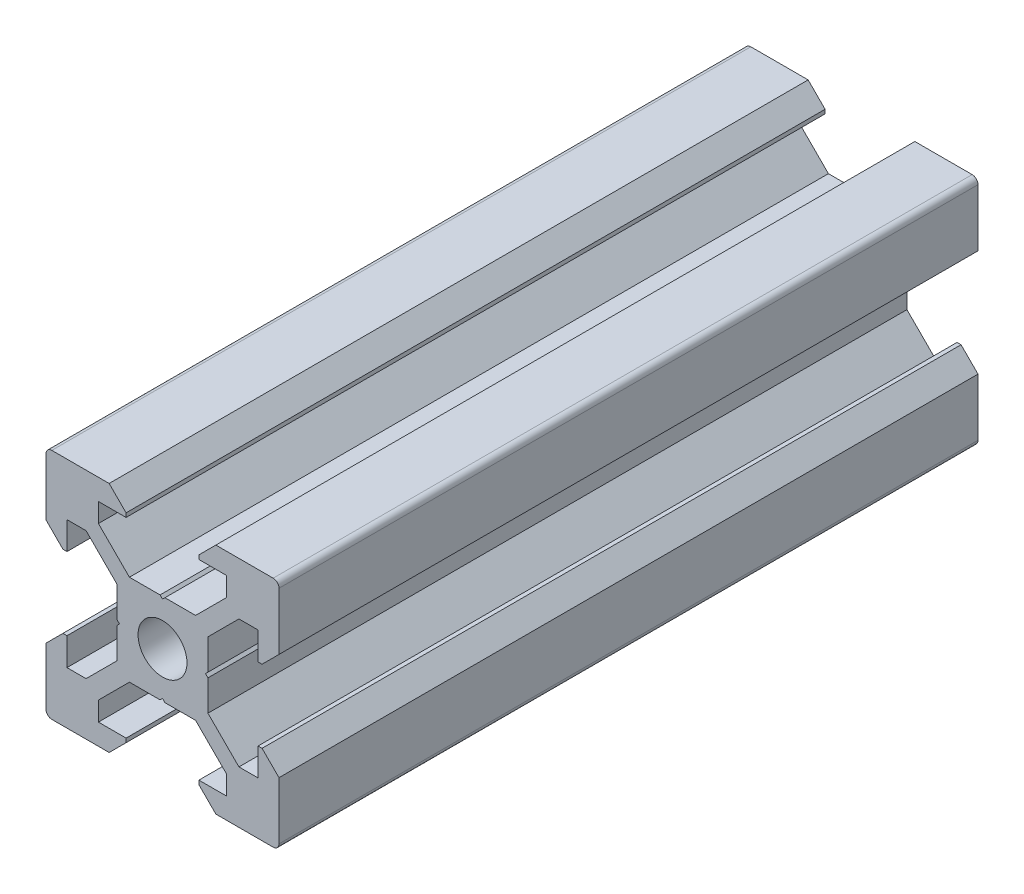
from build123d import *

# Parameters (mm, degrees)
SKETCH1_R           = 2.1
BOSS_EXTRUDE1_DEPTH = 60


with BuildPart() as part:
    # Sketch1 → Boss-Extrude1 (new body)
    with BuildSketch(Plane.XY):
        with BuildLine():
            Line((4.58, -10), (9.5, -10))
            ThreePointArc((9.5, -10), (9.853553391, -9.853553391), (10, -9.5))
            Line((10, -9.5), (10, -4.58))
            Line((10, -4.58), (8.545, -3.125))
            Line((8.545, -3.125), (8.2, -3.125))
            Line((8.2, -3.125), (8.2, -5.5))
            Line((8.2, -5.5), (6.560660172, -5.5))
            Line((6.560660172, -5.5), (3.9, -2.839339828))
            Line((3.9, -2.839339828), (3.9, -0.21))
            Line((3.9, -0.21), (3.69, 0))
            Line((3.69, 0), (3.9, 0.21))
            Line((3.9, 0.21), (3.9, 2.839339828))
            Line((3.9, 2.839339828), (6.560660172, 5.5))
            Line((6.560660172, 5.5), (8.2, 5.5))
            Line((8.2, 5.5), (8.2, 3.125))
            Line((8.2, 3.125), (8.545, 3.125))
            Line((8.545, 3.125), (10, 4.58))
            Line((10, 4.58), (10, 9.5))
            ThreePointArc((10, 9.5), (9.853553391, 9.853553391), (9.5, 10))
            Line((9.5, 10), (4.58, 10))
            Line((4.58, 10), (3.125, 8.545))
            Line((3.125, 8.545), (3.125, 8.2))
            Line((3.125, 8.2), (5.5, 8.2))
            Line((5.5, 8.2), (5.5, 6.560660172))
            Line((5.5, 6.560660172), (2.839339828, 3.9))
            Line((2.839339828, 3.9), (0.21, 3.9))
            Line((0.21, 3.9), (0, 3.69))
            Line((0, 3.69), (-0.21, 3.9))
            Line((-0.21, 3.9), (-2.839339828, 3.9))
            Line((-2.839339828, 3.9), (-5.5, 6.560660172))
            Line((-5.5, 6.560660172), (-5.5, 8.2))
            Line((-5.5, 8.2), (-3.125, 8.2))
            Line((-3.125, 8.2), (-3.125, 8.545))
            Line((-3.125, 8.545), (-4.58, 10))
            Line((-4.58, 10), (-9.5, 10))
            ThreePointArc((-9.5, 10), (-9.853553391, 9.853553391), (-10, 9.5))
            Line((-10, 9.5), (-10, 4.58))
            Line((-10, 4.58), (-8.545, 3.125))
            Line((-8.545, 3.125), (-8.2, 3.125))
            Line((-8.2, 3.125), (-8.2, 5.5))
            Line((-8.2, 5.5), (-6.560660172, 5.5))
            Line((-6.560660172, 5.5), (-3.9, 2.839339828))
            Line((-3.9, 2.839339828), (-3.9, 0.21))
            Line((-3.9, 0.21), (-3.69, 0))
            Line((-3.69, 0), (-3.9, -0.21))
            Line((-3.9, -0.21), (-3.9, -2.839339828))
            Line((-3.9, -2.839339828), (-6.560660172, -5.5))
            Line((-6.560660172, -5.5), (-8.2, -5.5))
            Line((-8.2, -5.5), (-8.2, -3.125))
            Line((-8.2, -3.125), (-8.545, -3.125))
            Line((-8.545, -3.125), (-10, -4.58))
            Line((-10, -4.58), (-10, -9.5))
            ThreePointArc((-10, -9.5), (-9.853553391, -9.853553391), (-9.5, -10))
            Line((-9.5, -10), (-4.58, -10))
            Line((-4.58, -10), (-3.125, -8.545))
            Line((-3.125, -8.545), (-3.125, -8.2))
            Line((-3.125, -8.2), (-5.5, -8.2))
            Line((-5.5, -8.2), (-5.5, -6.560660172))
            Line((-5.5, -6.560660172), (-2.839339828, -3.9))
            Line((-2.839339828, -3.9), (-0.21, -3.9))
            Line((-0.21, -3.9), (0, -3.69))
            Line((0, -3.69), (0.21, -3.9))
            Line((0.21, -3.9), (2.839339828, -3.9))
            Line((2.839339828, -3.9), (5.5, -6.560660172))
            Line((5.5, -6.560660172), (5.5, -8.2))
            Line((5.5, -8.2), (3.125, -8.2))
            Line((3.125, -8.2), (3.125, -8.545))
            Line((3.125, -8.545), (4.58, -10))
        make_face()
        Circle(SKETCH1_R, mode=Mode.SUBTRACT)
    extrude(amount=BOSS_EXTRUDE1_DEPTH)


solid = part.part
